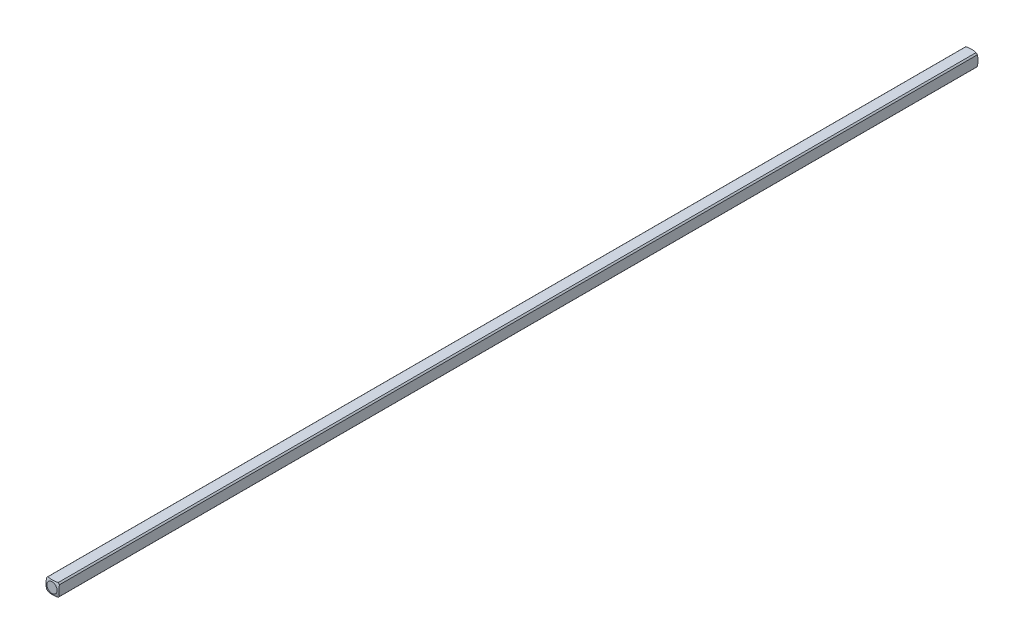
from build123d import *

# Parameters (mm, degrees)
SKETCH1_W           = 3.175
SKETCH1_H           = 3.175
BOSS_EXTRUDE1_DEPTH = 114.3
SKETCH2_OUTSIDE_W   = 28.054
SKETCH2_OUTSIDE_H   = 28.054
SKETCH2_OUTSIDE_R   = 2.032
CUT_EXTRUDE1_DEPTH  = 115.3


with BuildPart() as part:
    # Sketch1 → Boss-Extrude1 (new body)
    with BuildSketch(Plane.XY):
        Rectangle(SKETCH1_W, SKETCH1_H)
    extrude(amount=BOSS_EXTRUDE1_DEPTH)

    # Sketch2 outside → Cut-Extrude1 (cut, through all)
    with BuildSketch(Plane(origin=(0, 0, 0), x_dir=(-1, 0, 0), z_dir=(0, 0, -1))):
        Rectangle(SKETCH2_OUTSIDE_W, SKETCH2_OUTSIDE_H)
        Circle(SKETCH2_OUTSIDE_R, mode=Mode.SUBTRACT)
    extrude(amount=-CUT_EXTRUDE1_DEPTH, mode=Mode.SUBTRACT)

    # Sketch3 → Cut-Revolve1 (revolve, cut)
    with BuildSketch(Plane(origin=(0, 0, 0), x_dir=(1, 0, 0), z_dir=(0, 1, 0))):
        with BuildLine():
            Line((-5.053685963, -4.40273269), (-5.053685963, 5.740530545))
            Line((-5.053685963, 5.740530545), (0, 5.740530545))
            Line((0, 5.740530545), (0, 0.160877736))
            ThreePointArc((0, 0.160877736), (-3.404639553, -1.148866368), (-5.053685963, -4.40273269))
        make_face()
    revolve(axis=Axis((0, 0, 114.3), (0, 0, -1)), mode=Mode.SUBTRACT)

    # Mirror1: part across plane


with BuildPart() as part_1:
    add(part.part)
    add(part.part.mirror(Plane(origin=(0, 0, 114.3), x_dir=(1, 0, 0), z_dir=(0, 0, -1))))


solid = part_1.part
